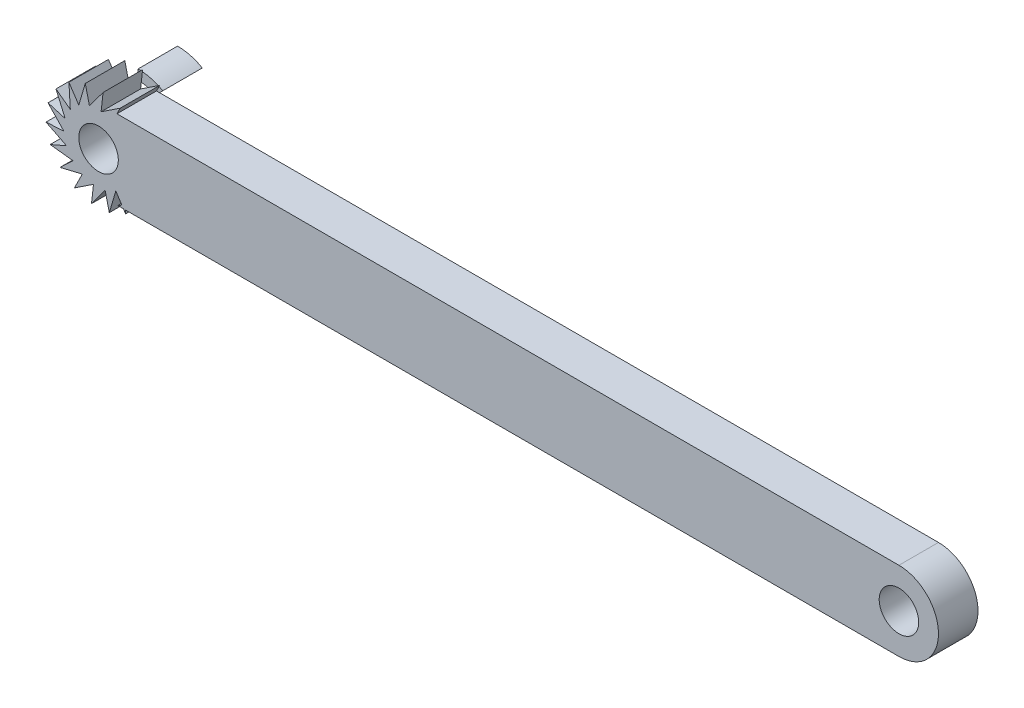
from build123d import *

# Parameters (mm, degrees)
SKETCH1_R           = 10
BOSS_EXTRUDE1_DEPTH = 20
BOSS_EXTRUDE2_START = 20
BOSS_EXTRUDE2_DEPTH = 20
SKETCH5_R           = 20
BOSS_EXTRUDE3_DEPTH = 5
CUT_EXTRUDE2_DEPTH  = 20
BOSS_EXTRUDE4_DEPTH = 20
CUT_EXTRUDE9_DEPTH  = 20
SKETCH13_R          = 10
CUT_EXTRUDE10_DEPTH = 20


with BuildPart() as part:
    # Sketch1 → Boss-Extrude1 (new body)
    with BuildSketch(Plane.XY):
        with BuildLine():
            Line((-71.370560529, 20), (333.629439471, 20))
            ThreePointArc((333.629439471, 20), (353.629439471, 0), (333.629439471, -20))
            Line((333.629439471, -20), (-71.370560529, -20))
            ThreePointArc((-71.370560529, -20), (-91.370560529, 0), (-71.370560529, 20))
        make_face()
        with Locations((-71.370560529, 0)):
            Circle(SKETCH1_R, mode=Mode.SUBTRACT)
        with Locations((333.629439471, 0)):
            Circle(SKETCH1_R, mode=Mode.SUBTRACT)
    extrude(amount=BOSS_EXTRUDE1_DEPTH)

    # Sketch2 → Boss-Extrude2 (add)
    with BuildSketch(Plane(origin=(0, 0, 0), x_dir=(-1, 0, 0), z_dir=(0, 0, -1)).offset(BOSS_EXTRUDE2_START)):
        with BuildLine():
            Line((71.370560529, -20), (71.370560529, -25))
            ThreePointArc((71.370560529, -25), (64.900084402, -24.148145657), (58.870560529, -21.650635095))
            Line((58.870560529, -21.650635095), (62.564306071, -17.956889553))
            ThreePointArc((62.564306071, -17.956889553), (66.850482602, -19.482527955), (71.370560529, -20))
        make_face()
    boss_extrude2 = extrude(amount=-BOSS_EXTRUDE2_DEPTH)

    # Sketch5 → Boss-Extrude3 (add)
    with BuildSketch(Plane.XY.offset(15)):
        with Locations((-72.002203934, 0)):
            Circle(SKETCH5_R)
    extrude(amount=BOSS_EXTRUDE3_DEPTH)

    # Mirror1: Boss-Extrude2 across plane
    add(boss_extrude2.mirror(Plane.ZX))

    # Sketch7 → Cut-Extrude2 (cut)
    with BuildSketch(Plane(origin=(0, 0, -20), x_dir=(-1, 0, 0), z_dir=(0, 0, -1))):
        with BuildLine():
            Line((62.564306071, -17.956889553), (58.870560529, -21.650635095))
            ThreePointArc((58.870560529, -21.650635095), (64.900084402, -24.148145657), (71.370560529, -25))
            Line((71.370560529, -25), (71.370560529, -20))
            ThreePointArc((71.370560529, -20), (66.850482602, -19.482527955), (62.564306071, -17.956889553))
        make_face()
    extrude(amount=-CUT_EXTRUDE2_DEPTH, mode=Mode.SUBTRACT)

    # Sketch8 → Boss-Extrude4 (add)
    with BuildSketch(Plane.XY.offset(20)):
        Polygon((-85.646323907, 10.091030395), (-86.357789766, 21.677572637), (-81.372147128, 14.149030667), (-78.077875507, 25.280154567), (-75.967816914, 16.500449024), (-69.065145589, 25.833576761), (-70.085175248, 16.861669707), (-60.406668254, 23.271088335), (-64.433755534, 15.189124172), (-53.146783654, 17.901763211), (-59.695202395, 11.684546094), (-48.161141016, 10.373221242), (-56.441055274, 6.770639312), (-46.051082422, 1.593515699), (-55.06381234, 1.040093504), (-47.07111208, -7.378391356), (-55.729589416, -4.81590293), (-51.09819936, -15.460355519), (-58.35808396, -10.091030395), (-57.646618102, -21.677572637), (-62.63226074, -14.149030667), (-65.92653236, -25.280154567), (-68.036590954, -16.500449024), (-74.939262278, -25.833576761), (-73.91923262, -16.861669707), (-83.597739613, -23.271088335), (-79.570652334, -15.189124172), (-90.857624214, -17.901763211), (-84.309205472, -11.684546094), (-95.843266852, -10.373221242), (-87.563352593, -6.770639312), (-97.953325446, -1.593515699), (-88.940595528, -1.040093504), (-96.933295787, 7.378391356), (-88.274818452, 4.81590293), (-92.906208508, 15.460355519), align=None)
    extrude(amount=-BOSS_EXTRUDE4_DEPTH)

    # Sketch10 → Cut-Extrude9 (cut)
    with BuildSketch(Plane.XY.offset(20)):
        with BuildLine():
            Line((-86.6814877, -16.89809712), (-79.570652334, -15.189124172))
            Line((-79.570652334, -15.189124172), (-81.99592579, -20.056407098))
            ThreePointArc((-81.99592579, -20.056407098), (-84.438311294, -18.625022051), (-86.6814877, -16.89809712))
        make_face()
        with BuildLine():
            Line((-84.309205472, -11.684546094), (-88.22937615, -15.406444953))
            ThreePointArc((-88.22937615, -15.406444953), (-90.031123734, -13.238238107), (-91.547408648, -10.861623847))
            Line((-91.547408648, -10.861623847), (-84.309205472, -11.684546094))
        make_face()
        with BuildLine():
            Line((-87.563352593, -6.770639312), (-92.502393068, -8.919610595))
            ThreePointArc((-92.502393068, -8.919610595), (-93.457564825, -6.272216499), (-94.074540655, -3.526239548))
            Line((-94.074540655, -3.526239548), (-87.563352593, -6.770639312))
        make_face()
        with BuildLine():
            Line((-88.940595528, -1.040093504), (-94.312976138, -1.369981861))
            ThreePointArc((-94.312976138, -1.369981861), (-94.310669326, 1.447480522), (-93.956044653, 4.24253704))
            Line((-93.956044653, 4.24253704), (-88.940595528, -1.040093504))
        make_face()
        with BuildLine():
            Line((-88.274818452, 4.81590293), (-93.447669354, 6.346815359))
            ThreePointArc((-93.447669354, 6.346815359), (-92.482976347, 9.005039035), (-91.192268127, 11.521158668))
            Line((-91.192268127, 11.521158668), (-88.274818452, 4.81590293))
        make_face()
        with BuildLine():
            Line((-85.646323907, 10.091030395), (-90.005019716, 13.314670467))
            ThreePointArc((-90.005019716, 13.314670467), (-88.18159333, 15.49770898), (-86.097159024, 17.433083507))
            Line((-86.097159024, 17.433083507), (-85.646323907, 10.091030395))
        make_face()
        with BuildLine():
            Line((-81.372147128, 14.149030667), (-84.386387194, 18.700667134))
            ThreePointArc((-84.386387194, 18.700667134), (-81.909430889, 20.140547455), (-79.269488567, 21.253773582))
            Line((-79.269488567, 21.253773582), (-81.372147128, 14.149030667))
        make_face()
        with BuildLine():
            Line((-75.967816914, 16.500449024), (-77.253980818, 21.852025701))
            ThreePointArc((-77.253980818, 21.852025701), (-74.411990383, 22.361916972), (-71.52809096, 22.503419105))
            Line((-71.52809096, 22.503419105), (-75.967816914, 16.500449024))
        make_face()
        with BuildLine():
            Line((-70.085175248, 16.861669707), (-69.458212145, 22.376268852))
            ThreePointArc((-69.458212145, 22.376268852), (-66.592631783, 21.877869576), (-63.815360138, 21.013742934))
            Line((-63.815360138, 21.013742934), (-70.085175248, 16.861669707))
        make_face()
        with BuildLine():
            Line((-62.63226074, -14.149030667), (-59.556389162, -18.793733456))
            ThreePointArc((-59.556389162, -18.793733456), (-62.072733786, -20.218474816), (-64.751115176, -21.308498365))
            Line((-64.751115176, -21.308498365), (-62.63226074, -14.149030667))
        make_face()
        with BuildLine():
            Line((-68.036590954, -16.500449024), (-66.745286272, -21.873415875))
            ThreePointArc((-66.745286272, -21.873415875), (-69.575313157, -22.347843134), (-72.442716434, -22.457987779))
            Line((-72.442716434, -22.457987779), (-68.036590954, -16.500449024))
        make_face()
        with BuildLine():
            Line((-73.91923262, -16.861669707), (-74.538256817, -22.306440369))
            ThreePointArc((-74.538256817, -22.306440369), (-77.339471693, -21.79001562), (-80.052922922, -20.923596707))
            Line((-80.052922922, -20.923596707), (-73.91923262, -16.861669707))
        make_face()
    extrude(amount=-CUT_EXTRUDE9_DEPTH, mode=Mode.SUBTRACT)

    # Sketch13 → Cut-Extrude10 (cut)
    with BuildSketch(Plane(origin=(0, 0, 0), x_dir=(-1, 0, 0), z_dir=(0, 0, -1))):
        with Locations((71.370560529, 0)):
            Circle(SKETCH13_R)
    extrude(amount=-CUT_EXTRUDE10_DEPTH, mode=Mode.SUBTRACT)


solid = part.part
